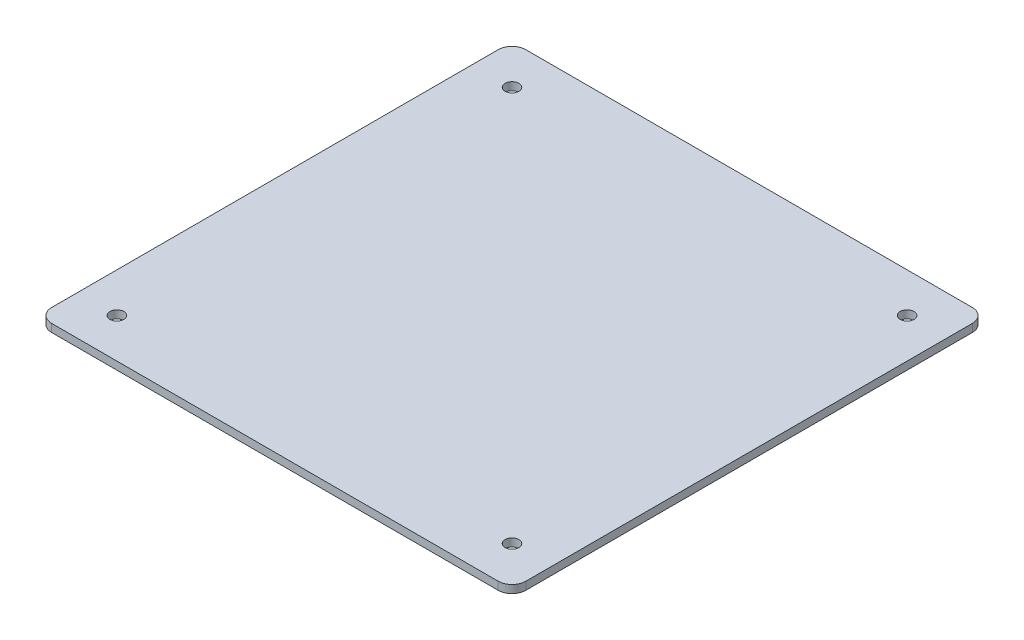
from build123d import *

# Parameters (mm, degrees)
SKETCH_4_W          = 120
SKETCH_4_H          = 120
EXTRUDE_2_DEPTH     = 2
FILLET_2_R          = 3.5
SKETCH_5_R          = 1.75
CUT_EXTRUDE_1_DEPTH = 3


with BuildPart() as part:
    # 草图4 → 凸台-拉伸2 (new body)
    with BuildSketch(Plane(origin=(0, 0, 0), x_dir=(1, 0, 0), z_dir=(0, 1, 0))):
        Rectangle(SKETCH_4_W, SKETCH_4_H)
    extrude(amount=EXTRUDE_2_DEPTH)

    # 圆角2
    fillet_2_edges = [part.edges().sort_by_distance(p)[0] for p in [
        (60, 1, 60),
        (-60, 1, 60),
        (-60, 1, -60),
        (60, 1, -60),
    ]]
    fillet(fillet_2_edges, radius=FILLET_2_R)

    # 草图5 → 切除-拉伸1 (cut, through all)
    with BuildSketch(Plane(origin=(0, 2, 0), x_dir=(1, 0, 0), z_dir=(0, 1, 0))):
        with Locations((-50, 50)):
            Circle(SKETCH_5_R)
        with Locations((-50, -50)):
            Circle(SKETCH_5_R)
        with Locations((50, -50)):
            Circle(SKETCH_5_R)
        with Locations((50, 50)):
            Circle(SKETCH_5_R)
    extrude(amount=-CUT_EXTRUDE_1_DEPTH, mode=Mode.SUBTRACT)


solid = part.part
